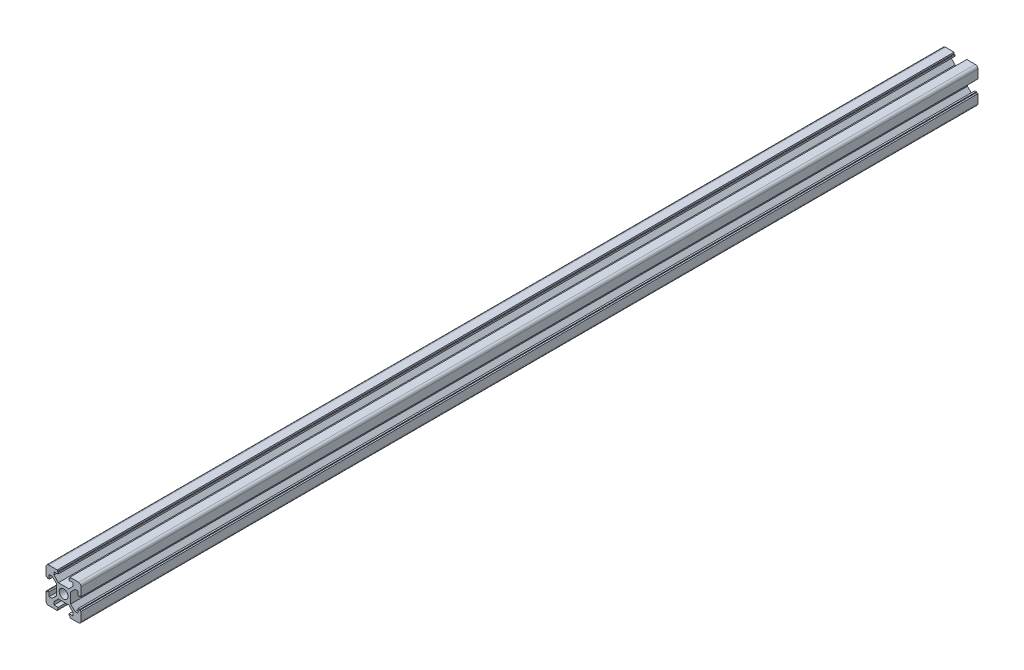
from build123d import *

# Parameters (mm, degrees)
SKETCH_1_R      = 2.5
EXTRUDE_1_DEPTH = 510
FILLET_1_R      = 1.5


with BuildPart() as part:
    # 草图1 → 凸台-拉伸1 (new body)
    with BuildSketch(Plane.XY):
        Polygon((-3.012509258, 4), (3.012509258, 4), (5.45, 6.584741199), (5.45, 8.2), (3.1, 8.2), (3.1, 9.1), (3.6, 9.1), (3.6, 10), (10, 10), (10, 3.6), (9.1, 3.6), (9.1, 3.1), (8.2, 3.1), (8.2, 5.45), (6.584741199, 5.45), (4, 3.012509258), (4, -3.012509258), (6.584741199, -5.45), (8.2, -5.45), (8.2, -3.1), (9.1, -3.1), (9.1, -3.6), (10, -3.6), (10, -10), (3.6, -10), (3.6, -9.1), (3.1, -9.1), (3.1, -8.2), (5.45, -8.2), (5.45, -6.584741199), (3.012509258, -4), (-3.012509258, -4), (-5.45, -6.584741199), (-5.45, -8.2), (-3.1, -8.2), (-3.1, -9.1), (-3.6, -9.1), (-3.6, -10), (-10, -10), (-10, -3.6), (-9.1, -3.6), (-9.1, -3.1), (-8.2, -3.1), (-8.2, -5.45), (-6.584741199, -5.45), (-4, -3.012509258), (-4, 3.012509258), (-6.584741199, 5.45), (-8.2, 5.45), (-8.2, 3.1), (-9.1, 3.1), (-9.1, 3.6), (-10, 3.6), (-10, 10), (-3.6, 10), (-3.6, 9.1), (-3.1, 9.1), (-3.1, 8.2), (-5.45, 8.2), (-5.45, 6.584741199), align=None)
        Circle(SKETCH_1_R, mode=Mode.SUBTRACT)
    extrude(amount=EXTRUDE_1_DEPTH)

    # 圆角1
    fillet_1_edges = [part.edges().sort_by_distance(p)[0] for p in [
        (10, -10, 255),
        (-10, -10, 255),
        (-10, 10, 255),
        (10, 10, 255),
    ]]
    fillet(fillet_1_edges, radius=FILLET_1_R)


solid = part.part
